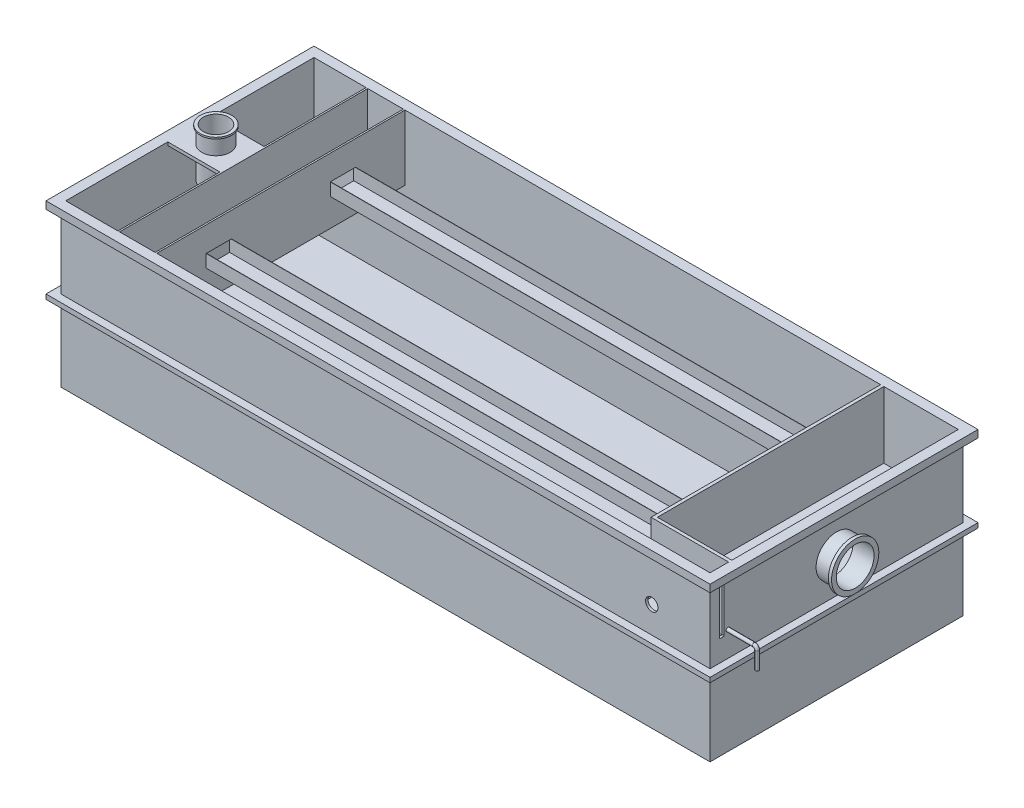
from build123d import *

# Parameters (mm, degrees)
ESBO_O1_W                      = 5350
ESBO_O1_H                      = 2159
RESSALTO_EXTRUS_O1_DEPTH       = 1300
ESBO_O2_W                      = 5191
ESBO_O2_H                      = 2000
CORTE_EXTRUS_O1_DEPTH          = 1220.5
RESSALTO_EXTRUS_O6_DEPTH       = 2079.5
ESBO_O4_W                      = 5350
ESBO_O4_H                      = 2159
ESBO_O4_W_2                    = 5230
ESBO_O4_H_2                    = 2039
CORTE_EXTRUS_O2_DEPTH          = 1240
ESBO_O8_R                      = 152.4
CORTE_EXTRUS_O3_DEPTH          = 19.5
ESBO_O8_3_R                    = 165.1
ESBO_O8_3_R_2                  = 152.4
RESSALTO_EXTRUS_O7_DEPTH       = 124.6
ESBO_O10_R                     = 190.5
ESBO_O10_R_2                   = 152.4
RESSALTO_EXTRUS_O8_DEPTH       = 25.4
ESBO_O12_W                     = 600
ESBO_O12_H                     = 1824.6
RESSALTO_EXTRUS_O10_DEPTH      = 560.8
ESBO_O12_4_W                   = 600
ESBO_O12_4_H                   = 1824.6
CORTE_EXTRUS_O4_DEPTH          = 535.4
ESBO_O16_W                     = 500
ESBO_O16_H                     = 355.6
RESSALTO_EXTRUS_O11_DEPTH      = 25.4
RESSALTO_EXTRUS_O12_DEPTH      = 400
ESBO_O17_R                     = 114.3
RESSALTO_EXTRUS_O13_DEPTH      = 125.5
RESSALTO_EXTRUS_O13_DEPTH_BACK = 250
ESBO_O18_R                     = 127
RESSALTO_EXTRUS_O14_DEPTH      = 12.7
CORTE_EXTRUS_O6_REACH          = 1440.2
ESBO_O19_R                     = 101.6
CORTE_EXTRUS_O7_REACH          = 814.7
ESBO_O20_W                     = 100
ESBO_O20_H                     = 100
ESBO_O20_W_2                   = 200
RESSALTO_EXTRUS_O15_DEPTH      = 3832.4
CORTE_EXTRUS_O8_REACH          = 766.6
ESBO_O24_R                     = 120
ESBO_O23_W                     = 25.4
ESBO_O23_H                     = 75.4
RESSALTO_EXTRUS_O16_DEPTH      = 169.5
RESSALTO_EXTRUS_O20_DEPTH      = 2019.5
ESBO_O33_W                     = 5350
ESBO_O33_H                     = 2159
ESBO_O33_W_2                   = 5230
ESBO_O33_H_2                   = 2039
RESSALTO_EXTRUS_O21_DEPTH      = 38.1
ESBO_O34_R                     = 15
ESBO_O34_R_2                   = 12.7
RESSALTO_EXTRUS_O22_DEPTH      = 280
ESBO_O35_R                     = 12.7
REVOLU_O1_ANGLE                = 90
ESBO_O36_R                     = 14.07759158
ESBO_O36_R_2                   = 12.7
RESSALTO_EXTRUS_O23_DEPTH      = 140
PADR_OCIRCULAR1_COUNT          = 2
ESBO_O38_R                     = 50
CORTE_EXTRUS_O11_DEPTH         = 19.5
CUT_EXTRUDE1_DEPTH             = 50
CUT_EXTRUDE1_DEPTH_BACK        = 60


with BuildPart() as part:
    # Esboço1 → Ressalto-extrusão1 (new body)
    with BuildSketch(Plane(origin=(0, 0, 0), x_dir=(1, 0, 0), z_dir=(0, 1, 0))):
        Rectangle(ESBO_O1_W, ESBO_O1_H)
    extrude(amount=RESSALTO_EXTRUS_O1_DEPTH)

    # Esboço2 → Corte-extrusão1 (cut)
    with BuildSketch(Plane(origin=(0, 1300, 0), x_dir=(1, 0, 0), z_dir=(0, 1, 0))):
        Rectangle(ESBO_O2_W, ESBO_O2_H)
    extrude(amount=-CORTE_EXTRUS_O1_DEPTH, mode=Mode.SUBTRACT)

    # Esboço3 → Ressalto-extrusão6 (add)
    with BuildSketch(Plane.XY.offset(1079.5)):
        Polygon((-2595.5, 79.5), (-2577.281287908, 79.5), (-1862.3, 774.634479084), (-1862.3, 1300), (-1875, 1300), (-1875, 780), align=None)
    extrude(amount=-RESSALTO_EXTRUS_O6_DEPTH)

    # Esboço4 → Corte-extrusão2 (cut)
    with BuildSketch(Plane.XZ):
        Rectangle(ESBO_O4_W, ESBO_O4_H)
        Rectangle(ESBO_O4_W_2, ESBO_O4_H_2, mode=Mode.SUBTRACT)
    extrude(amount=-CORTE_EXTRUS_O2_DEPTH, mode=Mode.SUBTRACT)

    # Esboço8 → Corte-extrusão3 (cut)
    with BuildSketch(Plane(origin=(2615, 0, 0), x_dir=(0, 0, -1), z_dir=(1, 0, 0))):
        with Locations((0, 930)):
            Circle(ESBO_O8_R)
    extrude(amount=-CORTE_EXTRUS_O3_DEPTH, mode=Mode.SUBTRACT)

    # Esboço8<3> → Ressalto-extrusão7 (add)
    with BuildSketch(Plane(origin=(2615, 0, 0), x_dir=(0, 0, -1), z_dir=(1, 0, 0))):
        with Locations((0, 930)):
            Circle(ESBO_O8_3_R)
        with Locations((0, 930)):
            Circle(ESBO_O8_3_R_2, mode=Mode.SUBTRACT)
    extrude(amount=RESSALTO_EXTRUS_O7_DEPTH)

    # Esboço10 → Ressalto-extrusão8 (add)
    with BuildSketch(Plane(origin=(2739.6, 0, 0), x_dir=(0, 0, -1), z_dir=(1, 0, 0))):
        with Locations((0, 930)):
            Circle(ESBO_O10_R)
        with Locations((0, 930)):
            Circle(ESBO_O10_R_2, mode=Mode.SUBTRACT)
    extrude(amount=RESSALTO_EXTRUS_O8_DEPTH)

    # Esboço12 → Ressalto-extrusão10 (add)
    with BuildSketch(Plane(origin=(0, 1300, 0), x_dir=(1, 0, 0), z_dir=(0, 1, 0))):
        Polygon((1995.5, -824.6), (1995.5, 1000), (1970.1, 1000), (1970.1, -850), (2595.5, -850), (2595.5, -824.6), align=None)
        with Locations((2295.5, 87.7)):
            Rectangle(ESBO_O12_W, ESBO_O12_H)
    extrude(amount=-RESSALTO_EXTRUS_O10_DEPTH)

    # Esboço12<4> → Corte-extrusão4 (cut)
    with BuildSketch(Plane(origin=(0, 1300, 0), x_dir=(1, 0, 0), z_dir=(0, 1, 0))):
        with Locations((2295.5, 87.7)):
            Rectangle(ESBO_O12_4_W, ESBO_O12_4_H)
    extrude(amount=-CORTE_EXTRUS_O4_DEPTH, mode=Mode.SUBTRACT)

    # Esboço16 → Ressalto-extrusão11 (add)
    with BuildSketch(Plane(origin=(0, 1300, 0), x_dir=(1, 0, 0), z_dir=(0, 1, 0))):
        with Locations((-2425, 0)):
            Rectangle(ESBO_O16_W, ESBO_O16_H)
    extrude(amount=-RESSALTO_EXTRUS_O11_DEPTH)

    # Esboço16<3> → Ressalto-extrusão12 (add)
    with BuildSketch(Plane(origin=(0, 1300, 0), x_dir=(1, 0, 0), z_dir=(0, 1, 0))):
        Polygon((-2175, 177.8), (-2175, 0), (-2162.3, 0), (-2162.3, 1000), (-2175, 1000), align=None)
        Polygon((-2162.3, 0), (-2175, 0), (-2175, -177.8), (-2175, -1000), (-2162.3, -1000), align=None)
    extrude(amount=-RESSALTO_EXTRUS_O12_DEPTH)

    # Esboço17 → Ressalto-extrusão13 (add, two sides)
    with BuildSketch(Plane(origin=(0, 1300, 0), x_dir=(1, 0, 0), z_dir=(0, 1, 0))) as ressalto_extrus_o13_sk:
        with Locations((-2385.25, 0)):
            Circle(ESBO_O17_R)
    extrude(amount=RESSALTO_EXTRUS_O13_DEPTH)
    extrude(ressalto_extrus_o13_sk.sketch, amount=-RESSALTO_EXTRUS_O13_DEPTH_BACK)

    # Esboço18 → Ressalto-extrusão14 (add)
    with BuildSketch(Plane(origin=(0, 1425.5, 0), x_dir=(1, 0, 0), z_dir=(0, 1, 0))):
        with Locations((-2385.25, 0)):
            Circle(ESBO_O18_R)
    extrude(amount=RESSALTO_EXTRUS_O14_DEPTH)

    # Esboço19 → Corte-extrusão6 (cut, up to next)
    with BuildSketch(Plane(origin=(0, 1438.2, 0), x_dir=(1, 0, 0), z_dir=(0, 1, 0)), mode=Mode.PRIVATE) as corte_extrus_o6_sk1:
        with Locations((-2385.25, 0)):
            Circle(ESBO_O19_R)
    corte_extrus_o6_tool1 = extrude(corte_extrus_o6_sk1.sketch, amount=-CORTE_EXTRUS_O6_REACH, mode=Mode.PRIVATE) & part.part
    add(corte_extrus_o6_tool1.solids().sort_by_distance((-2385.25, 1438.2, 0))[0], mode=Mode.SUBTRACT)

    # Esboço20 → Corte-extrusão7 (cut, up to next)
    with BuildSketch(Plane(origin=(-1862.3, 0, 0), x_dir=(0, 0, -1), z_dir=(1, 0, 0)), mode=Mode.PRIVATE) as corte_extrus_o7_sk1:
        with Locations((-450, 1050)):
            Rectangle(ESBO_O20_W, ESBO_O20_H)
    corte_extrus_o7_tool1 = extrude(corte_extrus_o7_sk1.sketch, amount=-CORTE_EXTRUS_O7_REACH, mode=Mode.PRIVATE) & part.part
    add(corte_extrus_o7_tool1.solids().sort_by_distance((-1862.3, 1050, 450))[0], mode=Mode.SUBTRACT)
    # Esboço20 → Corte-extrusão7 (cut, up to next)
    with BuildSketch(Plane(origin=(-1862.3, 0, 0), x_dir=(0, 0, -1), z_dir=(1, 0, 0)), mode=Mode.PRIVATE) as corte_extrus_o7_sk2:
        with Locations((-550, 1050)):
            Rectangle(ESBO_O20_W, ESBO_O20_H)
    corte_extrus_o7_tool2 = extrude(corte_extrus_o7_sk2.sketch, amount=-CORTE_EXTRUS_O7_REACH, mode=Mode.PRIVATE) & part.part
    add(corte_extrus_o7_tool2.solids().sort_by_distance((-1862.3, 1050, 550))[0], mode=Mode.SUBTRACT)
    # Esboço20 → Corte-extrusão7 (cut, up to next)
    with BuildSketch(Plane(origin=(-1862.3, 0, 0), x_dir=(0, 0, -1), z_dir=(1, 0, 0)), mode=Mode.PRIVATE) as corte_extrus_o7_sk3:
        with Locations((500, 1050)):
            Rectangle(ESBO_O20_W_2, ESBO_O20_H)
    corte_extrus_o7_tool3 = extrude(corte_extrus_o7_sk3.sketch, amount=-CORTE_EXTRUS_O7_REACH, mode=Mode.PRIVATE) & part.part
    add(corte_extrus_o7_tool3.solids().sort_by_distance((-1862.3, 1050, -500))[0], mode=Mode.SUBTRACT)

    # Esboço21 → Ressalto-extrusão15 (add)
    with BuildSketch(Plane(origin=(-1862.3, 0, 0), x_dir=(0, 0, -1), z_dir=(1, 0, 0))):
        Polygon((-600, 1000), (-600, 1100), (-602, 1100), (-602, 998), (-398, 998), (-398, 1100), (-400, 1100), (-400, 1000), align=None)
        Polygon((400, 1100), (398, 1100), (398, 998), (602, 998), (602, 1100), (600, 1100), (600, 1000), (400, 1000), align=None)
    extrude(amount=RESSALTO_EXTRUS_O15_DEPTH)

    # Esboço24 → Corte-extrusão8 (cut, up to next)
    with BuildSketch(Plane(origin=(0, 764.6, 0), x_dir=(1, 0, 0), z_dir=(0, 1, 0)), mode=Mode.PRIVATE) as corte_extrus_o8_sk1:
        with Locations((2295.5, 0)):
            Circle(ESBO_O24_R)
    corte_extrus_o8_tool1 = extrude(corte_extrus_o8_sk1.sketch, amount=-CORTE_EXTRUS_O8_REACH, mode=Mode.PRIVATE) & part.part
    add(corte_extrus_o8_tool1.solids().sort_by_distance((2295.5, 764.6, 0))[0], mode=Mode.SUBTRACT)

    # Esboço23 → Ressalto-extrusão16 (add)
    with BuildSketch(Plane.XY.offset(1019.5)):
        with Locations((1982.8, 802.3)):
            Rectangle(ESBO_O23_W, ESBO_O23_H)
        Polygon((1995.5, 764.6), (1970.1, 764.6), (1970.1, 739.2), (2595.5, 739.2), (2595.5, 764.6), align=None)
    extrude(amount=-RESSALTO_EXTRUS_O16_DEPTH)

    # Esboço32 → Ressalto-extrusão20 (add)
    with BuildSketch(Plane.XY.offset(1019.5)):
        Polygon((1970.1, 831.113097721), (1970.1, 840), (1295.5, 179.5), (1304.576615106, 179.5), (1311.062171502, 185.85), align=None)
    extrude(amount=-RESSALTO_EXTRUS_O20_DEPTH)

    # Esboço33 → Ressalto-extrusão21 (add)
    with BuildSketch(Plane(origin=(0, 650, 0), x_dir=(1, 0, 0), z_dir=(0, 1, 0))):
        Rectangle(ESBO_O33_W, ESBO_O33_H)
        Rectangle(ESBO_O33_W_2, ESBO_O33_H_2, mode=Mode.SUBTRACT)
    extrude(amount=-RESSALTO_EXTRUS_O21_DEPTH)

    # Esboço34 → Ressalto-extrusão22 (add)
    with BuildSketch(Plane(origin=(2615, 0, 0), x_dir=(0, 0, -1), z_dir=(1, 0, 0))):
        with Locations((-925, 901.9)):
            Circle(ESBO_O34_R)
        with Locations((-925, 901.9)):
            Circle(ESBO_O34_R_2, mode=Mode.SUBTRACT)
    ressalto_extrus_o22 = extrude(amount=-RESSALTO_EXTRUS_O22_DEPTH)

    # Esboço35 → Revolução1 (revolve)
    with BuildSketch(Plane.ZY.offset(-2335)):
        with BuildLine():
            ThreePointArc((925, 915.97759158), (915.045639531, 891.945639531), (939.07759158, 901.9))
            ThreePointArc((939.07759158, 901.9), (934.954360469, 911.854360469), (925, 915.97759158))
        make_face()
        with Locations((925, 901.9)):
            Circle(ESBO_O35_R, mode=Mode.SUBTRACT)
    revolu_o1 = revolve(axis=Axis((2335, 925.97759158, 925), (0, 0, -1)), revolution_arc=REVOLU_O1_ANGLE)

    # Esboço36 → Ressalto-extrusão23 (add)
    with BuildSketch(Plane(origin=(0, 925.97759158, 0), x_dir=(1, 0, 0), z_dir=(0, 1, 0))):
        with Locations((2310.92240842, -925)):
            Circle(ESBO_O36_R)
        with Locations((2310.92240842, -925)):
            Circle(ESBO_O36_R_2, mode=Mode.SUBTRACT)
    ressalto_extrus_o23 = extrude(amount=RESSALTO_EXTRUS_O23_DEPTH)

    # PadrãoCircular1: Ressalto-extrusão22, Revolução1, Ressalto-extrusão23 ×2 about axis
    padr_ocircular1_axis = Axis((2605.25, 901.9, 0), (0, 0, 1))
    for i in range(1, PADR_OCIRCULAR1_COUNT):
        add(ressalto_extrus_o22.rotate(padr_ocircular1_axis, i * 360 / PADR_OCIRCULAR1_COUNT))
        add(revolu_o1.rotate(padr_ocircular1_axis, i * 360 / PADR_OCIRCULAR1_COUNT))
        add(ressalto_extrus_o23.rotate(padr_ocircular1_axis, i * 360 / PADR_OCIRCULAR1_COUNT))

    # Esboço38 → Corte-extrusão11 (cut)
    with BuildSketch(Plane.XY.offset(1019.5)):
        with Locations((2145.5, 864.6)):
            Circle(ESBO_O38_R)
    extrude(amount=-CORTE_EXTRUS_O11_DEPTH, mode=Mode.SUBTRACT)

    # Sketch1 → Cut-Extrude1 (cut, two sides)
    with BuildSketch(Plane(origin=(2615, 0, 0), x_dir=(0, 0, -1), z_dir=(1, 0, 0))) as cut_extrude1_sk:
        with BuildLine():
            Line((-939.6, 1179.6), (-910.4, 1179.6))
            ThreePointArc((-910.4, 1179.6), (-906.864466094, 1178.135533906), (-905.4, 1174.6))
            Line((-905.4, 1174.6), (-905.4, 825))
            ThreePointArc((-905.4, 825), (-906.864466094, 821.464466094), (-910.4, 820))
            Line((-910.4, 820), (-939.6, 820))
            ThreePointArc((-939.6, 820), (-943.135533906, 821.464466094), (-944.6, 825))
            Line((-944.6, 825), (-944.6, 1174.6))
            ThreePointArc((-944.6, 1174.6), (-943.135533906, 1178.135533906), (-939.6, 1179.6))
        make_face()
    extrude(amount=CUT_EXTRUDE1_DEPTH, mode=Mode.SUBTRACT)
    extrude(cut_extrude1_sk.sketch, amount=-CUT_EXTRUDE1_DEPTH_BACK, mode=Mode.SUBTRACT)


solid = part.part
